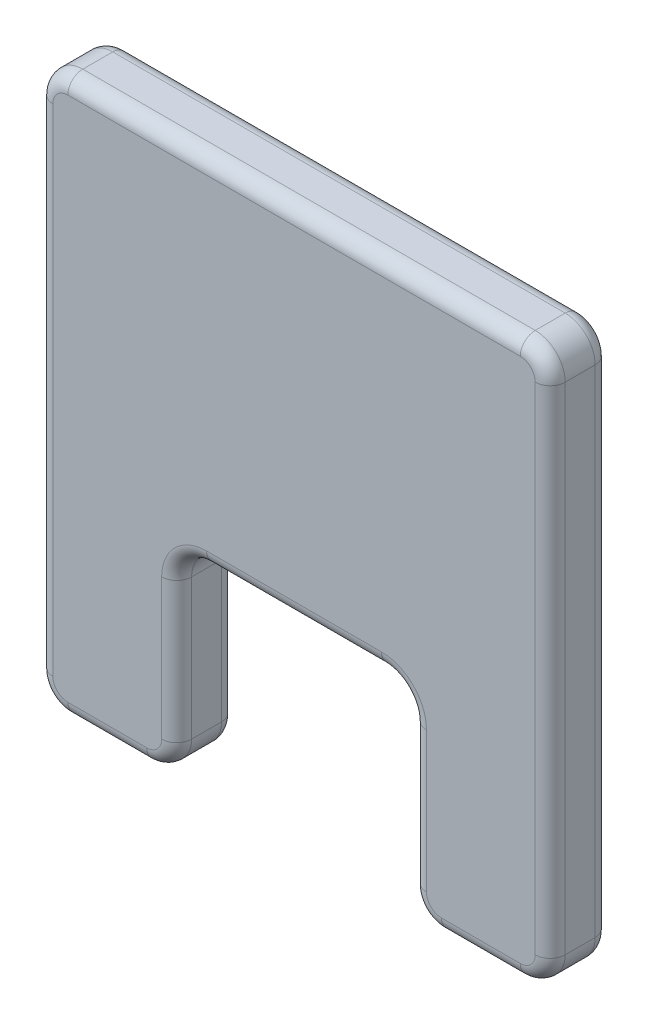
from build123d import *

# Parameters (mm, degrees)
BOSS_EXTRUDE1_DEPTH = 50.8
FILLET1_R           = 25.4
FILLET2_R           = 12.7


with BuildPart() as part:
    # Sketch1 → Boss-Extrude1 (new body)
    with BuildSketch(Plane.XY):
        Polygon((-93.295534025, 241.224648834), (341.304465963, 241.224648834), (341.304465963, -230.262851166), (223.626687979, -230.262851166), (223.626687979, -60.262851166), (24.382243959, -60.262851166), (24.382243959, -230.262851166), (-93.295534025, -230.262851166), align=None)
    extrude(amount=BOSS_EXTRUDE1_DEPTH)

    # Fillet1
    fillet1_edges = [part.edges().sort_by_distance(p)[0] for p in [
        (-93.295534025, 241.224648834, 25.4),
        (341.304465963, 241.224648834, 25.4),
        (341.304465963, -230.262851166, 25.4),
        (223.626687979, -230.262851166, 25.4),
        (223.626687979, -60.262851166, 25.4),
        (24.382243959, -60.262851166, 25.4),
        (24.382243959, -230.262851166, 25.4),
        (-93.295534025, -230.262851166, 25.4),
    ]]
    fillet(fillet1_edges, radius=FILLET1_R)

    # Fillet2
    fillet2_edges = [part.edges().sort_by_distance(p)[0] for p in [
        (24.382243959, -145.262851166, 0),
        (24.382243959, -145.262851166, 50.8),
        (-93.295534025, 5.480898834, 0),
        (124.004465969, 241.224648834, 0),
        (341.304465963, 5.480898834, 0),
        (282.465576971, -230.262851166, 0),
        (223.626687979, -145.262851166, 0),
        (124.004465969, -60.262851166, 0),
        (-34.456645033, -230.262851166, 0),
        (231.066175737, -222.823363409, 0),
        (333.864978205, -222.823363409, 0),
        (333.864978205, 233.785161076, 0),
        (-85.856046267, 233.785161076, 0),
        (-85.856046267, -222.823363409, 0),
        (16.942756201, -222.823363409, 0),
        (-34.456645033, -230.262851166, 50.8),
        (-93.295534025, 5.480898834, 50.8),
        (124.004465969, -60.262851166, 50.8),
        (223.626687979, -145.262851166, 50.8),
        (282.465576971, -230.262851166, 50.8),
        (341.304465963, 5.480898834, 50.8),
        (124.004465969, 241.224648834, 50.8),
        (231.066175737, -222.823363409, 50.8),
        (333.864978205, -222.823363409, 50.8),
        (333.864978205, 233.785161076, 50.8),
        (-85.856046267, 233.785161076, 50.8),
        (-85.856046267, -222.823363409, 50.8),
        (16.942756201, -222.823363409, 50.8),
        (216.187200221, -67.702338924, 0),
        (216.187200221, -67.702338924, 50.8),
        (31.821731717, -67.702338924, 0),
        (31.821731717, -67.702338924, 50.8),
    ]]
    fillet(fillet2_edges, radius=FILLET2_R)


solid = part.part
